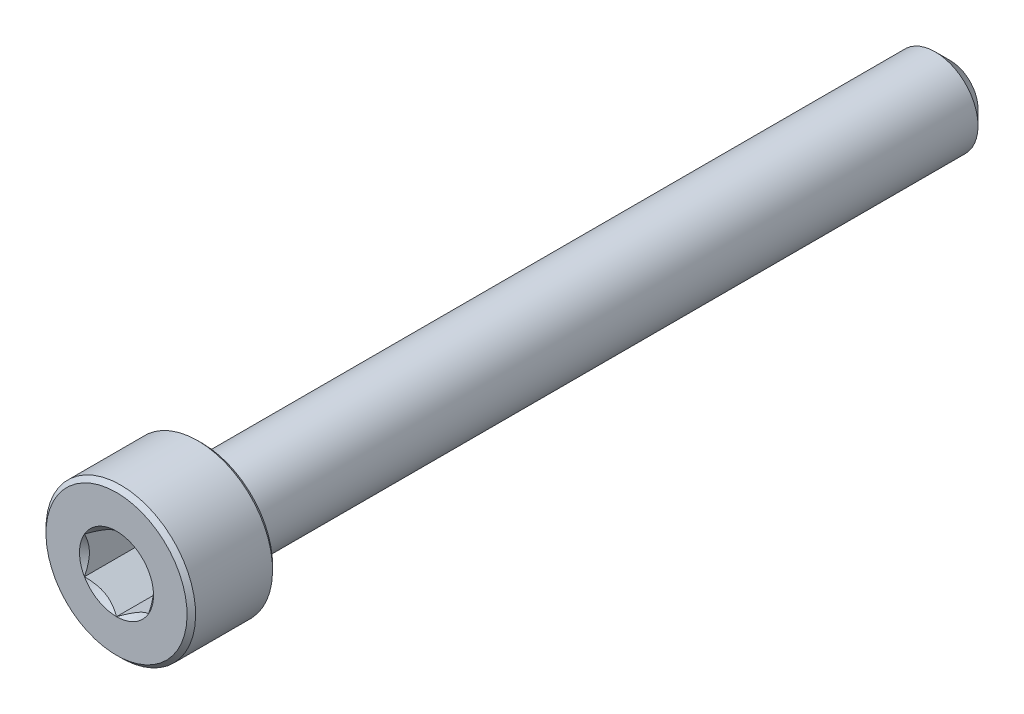
from build123d import *

# Parameters (mm, degrees)
CUT_EXTRUDE1_DEPTH = 3
SKETCH4_R          = 1.732050808
CUT_EXTRUDE2_DEPTH = 3
CUT_EXTRUDE2_DRAFT = -45


with BuildPart() as part:
    # Sketch2 → Revolve1 (revolve)
    with BuildSketch(Plane(origin=(0, 0, 0), x_dir=(0, 0, -1), z_dir=(1, 0, 0))):
        Polygon((-19.5, 0), (-19.5, 3.3), (-19.3, 3.5), (-15.7, 3.5), (-15.5, 3.3), (-15.5, 2), (18.8, 2), (19.5, 1.3), (19.5, 0), align=None)
    revolve(axis=Axis((0, 0, -19.5), (0, 0, 1)))

    # Sketch3 → Cut-Extrude1 (cut)
    with BuildSketch(Plane.XY.offset(19.5)):
        Polygon((1.5, -0.866025404), (1.5, 0.866025404), (0, 1.732050808), (-1.5, 0.866025404), (-1.5, -0.866025404), (0, -1.732050808), align=None)
    extrude(amount=-CUT_EXTRUDE1_DEPTH, mode=Mode.SUBTRACT)


with BuildPart() as cut_extrude2_tool:
    # Sketch4 → Cut-Extrude2 (with draft: the straight prism first)
    with BuildSketch(Plane.XY.offset(19.5)):
        Circle(SKETCH4_R)
    extrude(amount=-CUT_EXTRUDE2_DEPTH)
    # Cut-Extrude2: the draft: its side faces are tilted about the plane it starts from
    cut_extrude2_sides = [cut_extrude2_tool.faces().sort_by_distance(p)[0] for p in [
        (-1.732050808, 0, 18),
    ]]
    draft(cut_extrude2_sides, Plane.XY.offset(19.5), CUT_EXTRUDE2_DRAFT)


with BuildPart() as part_1:
    add(part.part)

    # Cut-Extrude2: cut by cut_extrude2_tool
    add(cut_extrude2_tool.part, mode=Mode.SUBTRACT)


solid = part_1.part
